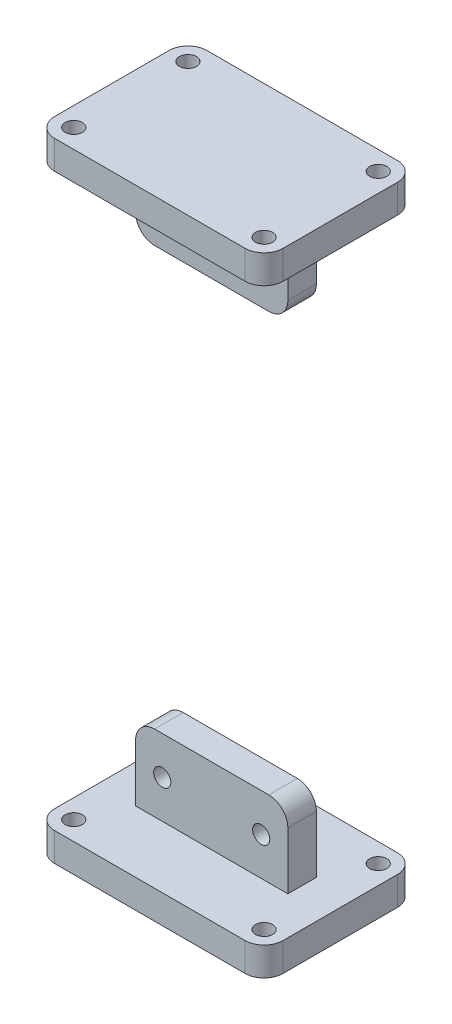
from build123d import *

# Parameters (mm, degrees)
SKETCH1_W               = 120
SKETCH1_H               = 80
BOSS_EXTRUDE1_DEPTH     = 15
FILLET1_R               = 10
FILLET2_R               = 10
FILLET3_R               = 10
FILLET4_R               = 10
SKETCH2_R               = 4.5
CUT_EXTRUDE1_DEPTH      = 16
CUT_EXTRUDE1_DEPTH_BACK = 1
SKETCH4_W               = 80
SKETCH4_H               = 15
BOSS_EXTRUDE2_DEPTH     = 40
FILLET5_R               = 10
FILLET6_R               = 10
SKETCH5_R               = 4.5
CUT_EXTRUDE2_DEPTH      = 41
CUT_EXTRUDE2_DEPTH_BACK = 41
SKETCH6_R               = 4.5
CUT_EXTRUDE3_DEPTH      = 41
CUT_EXTRUDE3_DEPTH_BACK = 41
BODY_MOVE_COPY3_ANGLE   = 180


with BuildPart() as part:
    # Sketch1 → Boss-Extrude1 (new body)
    with BuildSketch(Plane(origin=(0, 0, 0), x_dir=(1, 0, 0), z_dir=(0, 1, 0))):
        Rectangle(SKETCH1_W, SKETCH1_H)
    extrude(amount=BOSS_EXTRUDE1_DEPTH)

    # Fillet1
    fillet1_edges = [part.edges().sort_by_distance(p)[0] for p in [
        (60, 7.5, 40),
    ]]
    fillet(fillet1_edges, radius=FILLET1_R)

    # Fillet2
    fillet2_edges = [part.edges().sort_by_distance(p)[0] for p in [
        (-60, 7.5, 40),
    ]]
    fillet(fillet2_edges, radius=FILLET2_R)

    # Fillet3
    fillet3_edges = [part.edges().sort_by_distance(p)[0] for p in [
        (-60, 7.5, -40),
    ]]
    fillet(fillet3_edges, radius=FILLET3_R)

    # Fillet4
    fillet4_edges = [part.edges().sort_by_distance(p)[0] for p in [
        (60, 7.5, -40),
    ]]
    fillet(fillet4_edges, radius=FILLET4_R)

    # Sketch2 → Cut-Extrude1 (cut, two sides)
    with BuildSketch(Plane(origin=(0, 0, 0), x_dir=(1, 0, 0), z_dir=(0, 1, 0))) as cut_extrude1_sk:
        with Locations((-50, 30)):
            Circle(SKETCH2_R)
        with Locations((-50, -30)):
            Circle(SKETCH2_R)
        with Locations((50, -30)):
            Circle(SKETCH2_R)
        with Locations((50, 30)):
            Circle(SKETCH2_R)
    extrude(amount=CUT_EXTRUDE1_DEPTH, mode=Mode.SUBTRACT)
    extrude(cut_extrude1_sk.sketch, amount=-CUT_EXTRUDE1_DEPTH_BACK, mode=Mode.SUBTRACT)

    # Sketch4 → Boss-Extrude2 (add)
    with BuildSketch(Plane(origin=(0, 0, 0), x_dir=(1, 0, 0), z_dir=(0, 1, 0))):
        Rectangle(SKETCH4_W, SKETCH4_H)
    extrude(amount=-BOSS_EXTRUDE2_DEPTH)

    # Fillet5
    fillet5_edges = [part.edges().sort_by_distance(p)[0] for p in [
        (-40, -40, 0),
    ]]
    fillet(fillet5_edges, radius=FILLET5_R)

    # Fillet6
    fillet6_edges = [part.edges().sort_by_distance(p)[0] for p in [
        (40, -40, 0),
    ]]
    fillet(fillet6_edges, radius=FILLET6_R)

    # Sketch5 → Cut-Extrude2 (cut, two sides)
    with BuildSketch(Plane.XY) as cut_extrude2_sk:
        with Locations((-26, -20)):
            Circle(SKETCH5_R)
    extrude(amount=CUT_EXTRUDE2_DEPTH, mode=Mode.SUBTRACT)
    extrude(cut_extrude2_sk.sketch, amount=-CUT_EXTRUDE2_DEPTH_BACK, mode=Mode.SUBTRACT)

    # Sketch6 → Cut-Extrude3 (cut, two sides)
    with BuildSketch(Plane.XY) as cut_extrude3_sk:
        with Locations((26, -20)):
            Circle(SKETCH6_R)
    extrude(amount=CUT_EXTRUDE3_DEPTH, mode=Mode.SUBTRACT)
    extrude(cut_extrude3_sk.sketch, amount=-CUT_EXTRUDE3_DEPTH_BACK, mode=Mode.SUBTRACT)


with BuildPart() as body_2:
    # Body-Move/Copy3: copy of part
    add(part.part.rotate(Axis((0, -150, 0), (1, 0, 0)), BODY_MOVE_COPY3_ANGLE))


solid = Compound([part.part, body_2.part])
